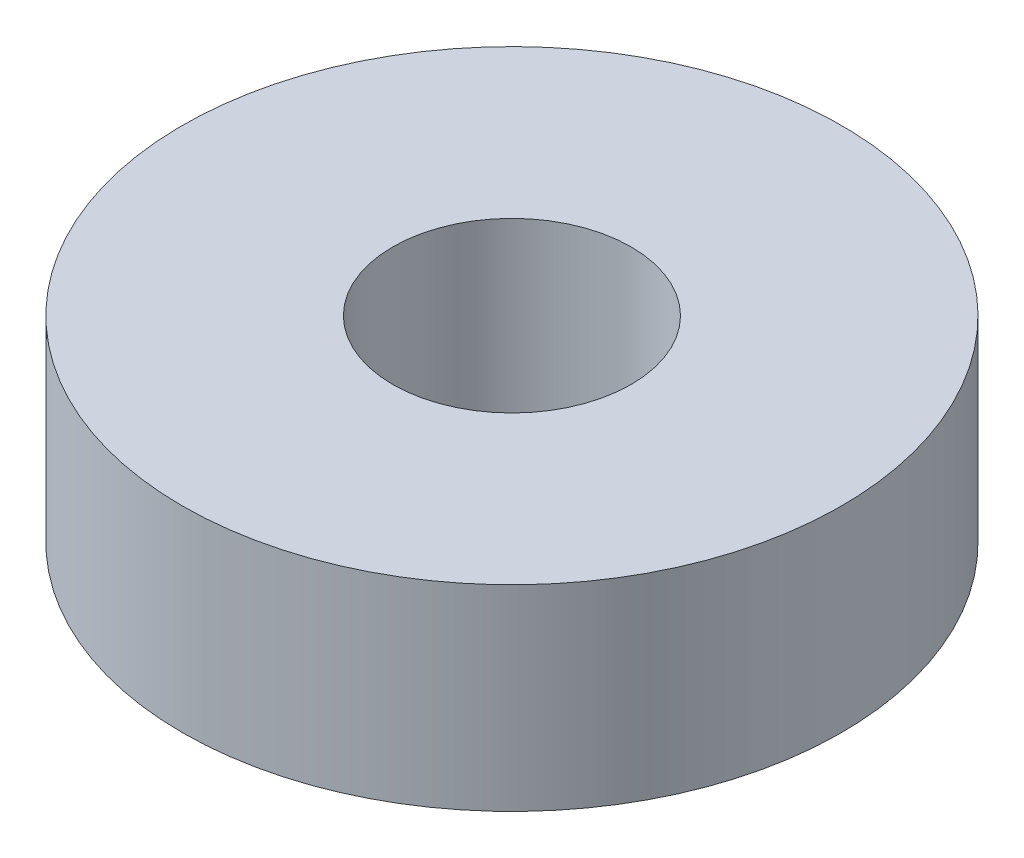
from build123d import *

# Parameters (mm, degrees)
SKETCH1_R           = 23.5
SKETCH1_R_2         = 8.5
BOSS_EXTRUDE1_DEPTH = 7


with BuildPart() as part:
    # Sketch1 → Boss-Extrude1 (new body, symmetric)
    with BuildSketch(Plane(origin=(0, 0, 0), x_dir=(1, 0, 0), z_dir=(0, 1, 0))):
        Circle(SKETCH1_R)
        Circle(SKETCH1_R_2, mode=Mode.SUBTRACT)
    extrude(amount=BOSS_EXTRUDE1_DEPTH, both=True)


solid = part.part
